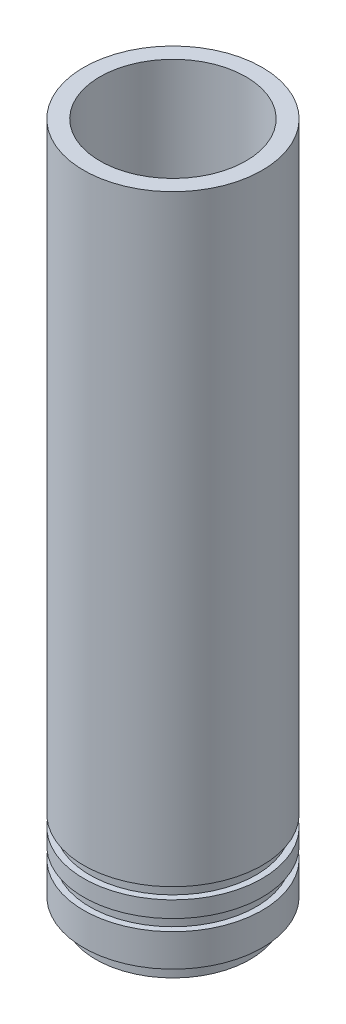
from build123d import *

# Parameters (mm, degrees)
FILLET1_R = 5


with BuildPart() as part:
    # Sketch1 → Revolve1 (revolve)
    with BuildSketch(Plane.XY):
        Polygon((16, 0), (9.5, 24.258330249), (9.5, 29.258330249), (18, 37.758330249), (18, 170), (22, 170), (22, 21.6), (20.5, 21.6), (20.5, 18.8), (22, 18.8), (22, 14.8), (20.5, 14.8), (20.5, 12), (22, 12), (22, 4), (19, 4), (19, 0), align=None)
    revolve(axis=Axis((0, 0, 0), (0, 1, 0)))

    # Fillet1
    fillet1_edges = [part.edges().sort_by_distance(p)[0] for p in [
        (-9.5, 29.258330249, 0),
        (-9.5, 24.258330249, 0),
    ]]
    fillet(fillet1_edges, radius=FILLET1_R)


solid = part.part
